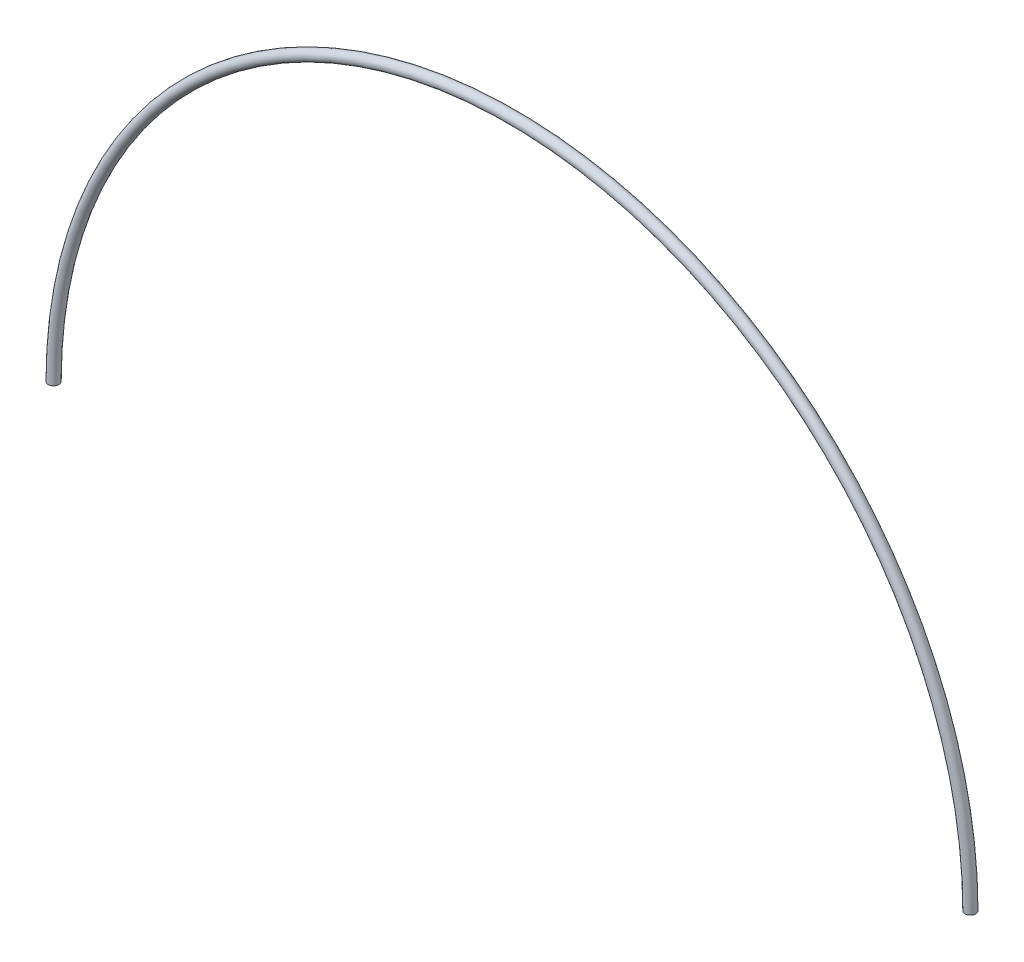
from build123d import *

# Parameters (mm, degrees)
SKETCH2_R = 4.7625


with BuildPart() as part:
    # Sweep1: sweep along a path in Sketch1
    with BuildLine(Plane.XY) as sweep1_path:
        ThreePointArc((-406.4, 0), (0, 406.4), (406.4, 0))
    # Sketch2 → Sweep1 (sweep)
    with BuildSketch(Plane(origin=(406.4, 0, 0), x_dir=(1, 0, 0), z_dir=(0, -1, 0))):
        Circle(SKETCH2_R)
    sweep(path=sweep1_path.line)


solid = part.part
